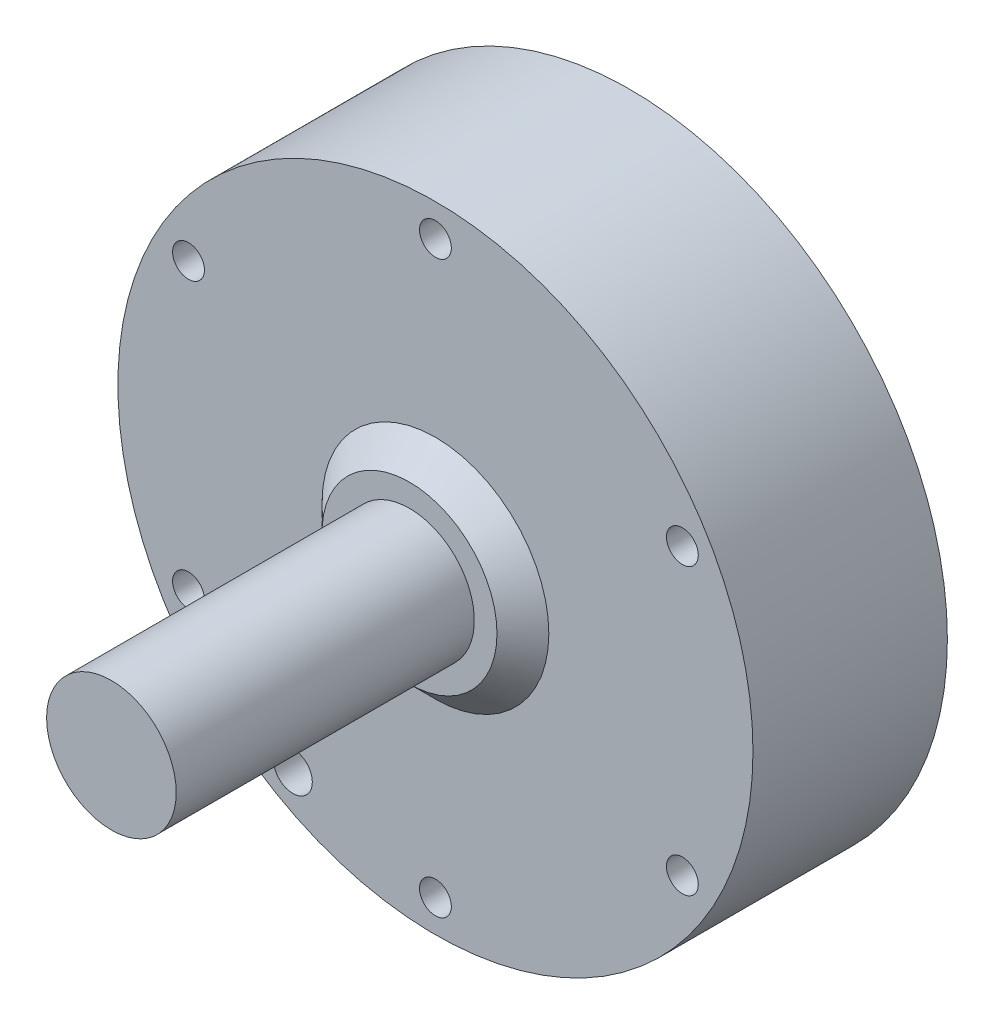
from build123d import *

# Parameters (mm, degrees)
ESQUISSE1_R                  = 49
BASE_EXTRUSION_DEPTH         = 30
ESQUISSE20_R                 = 3
ENL_V_MAT_EXTRU_4_DEPTH      = 12
ESQUISSE3_R                  = 10
BOSS_EXTRU_1_DEPTH           = 46
ESQUISSE11_R                 = 3
ENL_V_MAT_EXTRU_3_DEPTH      = 31.0000001
R_P_TITION_CIRCULAIRE1_COUNT = 6
R_P_TITION_CIRCULAIRE3_COUNT = 2
R_P_TITION_CIRCULAIRE3_ANGLE = 135
R_P_TITION_CIRCULAIRE4_COUNT = 3


with BuildPart() as part:
    # Esquisse1 → Base-Extrusion (new body)
    with BuildSketch(Plane.XY):
        Circle(ESQUISSE1_R)
    extrude(amount=BASE_EXTRUSION_DEPTH)

    # Esquisse2 → Boss.-Révol.1 (revolve)
    with BuildSketch(Plane(origin=(0, 0, 0), x_dir=(0, 0, -1), z_dir=(1, 0, 0))):
        Polygon((-30, 0), (-30, 17.5), (-34, 13.5), (-34, 0), align=None)
    revolve(axis=Axis((0, 0, 38.858858859), (0, 0, -1)))

    # Esquisse20 → Enlèv. mat.-Extru.4 (cut)
    with BuildSketch(Plane(origin=(-49, 0, 15), x_dir=(0, 1, 0), z_dir=(-1, 0, 0))):
        with Locations((0, -3)):
            Circle(ESQUISSE20_R)
    extrude(amount=-ENL_V_MAT_EXTRU_4_DEPTH, mode=Mode.SUBTRACT)

    # Esquisse3 → Boss.-Extru.1 (add)
    with BuildSketch(Plane.XY.offset(34)):
        Circle(ESQUISSE3_R)
    extrude(amount=BOSS_EXTRU_1_DEPTH)

    # Esquisse11 → Enlèv. mat.-Extru.3 (cut, through all)
    with BuildSketch(Plane.XY.offset(30)):
        with Locations((-22, -38.105117767)):
            Circle(ESQUISSE11_R)
    extrude(amount=-ENL_V_MAT_EXTRU_3_DEPTH, mode=Mode.SUBTRACT)

    # Esquisse12 → Perçage2 (revolve, cut)
    with BuildSketch(Plane(origin=(0, -44, 30), x_dir=(0, -1, 0), z_dir=(1, 0, 0))):
        Polygon((0, 0), (0, 26.47511282), (2.455, 25), (2.455, 0), align=None)
    per_age2 = revolve(axis=Axis((0, -44, 34.244199587), (0, 0, -1)), mode=Mode.SUBTRACT)

    # Répétition circulaire1: Perçage2 ×6 about axis
    r_p_tition_circulaire1_axis = Axis((0, 0, 0), (0, 0, 1))
    for i in range(1, R_P_TITION_CIRCULAIRE1_COUNT):
        add(per_age2.rotate(r_p_tition_circulaire1_axis, i * 360 / R_P_TITION_CIRCULAIRE1_COUNT), mode=Mode.SUBTRACT)

    # Esquisse16 → Perçage4 (revolve, cut)
    with BuildSketch(Plane(origin=(-21.242014496, 21.184353192, 0), x_dir=(0, 1, 0), z_dir=(1, 0, 0))):
        Polygon((0, 0), (0, 21.802581857), (3, 20), (3, 0), align=None)
    per_age4 = revolve(axis=Axis((-21.242014496, 21.184353192, -6.35), (0, 0, 1)), mode=Mode.SUBTRACT)

    # Répétition circulaire3: Perçage4 ×2 about axis
    r_p_tition_circulaire3_axis = Axis((0, 0, 0), (0, 0, -1))
    for i in range(1, R_P_TITION_CIRCULAIRE3_COUNT):
        add(per_age4.rotate(r_p_tition_circulaire3_axis, i * R_P_TITION_CIRCULAIRE3_ANGLE / (R_P_TITION_CIRCULAIRE3_COUNT - 1)), mode=Mode.SUBTRACT)

    # Esquisse18 → Perçage5 (revolve, cut)
    with BuildSketch(Plane(origin=(-30, -0.050785262, 0), x_dir=(0, 1, 0), z_dir=(1, 0, 0))):
        Polygon((0, 0), (0, 21.502151548), (2.5, 20), (2.5, 0), align=None)
    per_age5 = revolve(axis=Axis((-30, -0.050785262, -6.35), (0, 0, 1)), mode=Mode.SUBTRACT)

    # Répétition circulaire4: Perçage5 ×3 about axis
    r_p_tition_circulaire4_axis = Axis((0, 0, 0), (0, 0, 1))
    for i in range(1, R_P_TITION_CIRCULAIRE4_COUNT):
        add(per_age5.rotate(r_p_tition_circulaire4_axis, i * 360 / R_P_TITION_CIRCULAIRE4_COUNT), mode=Mode.SUBTRACT)


solid = part.part
